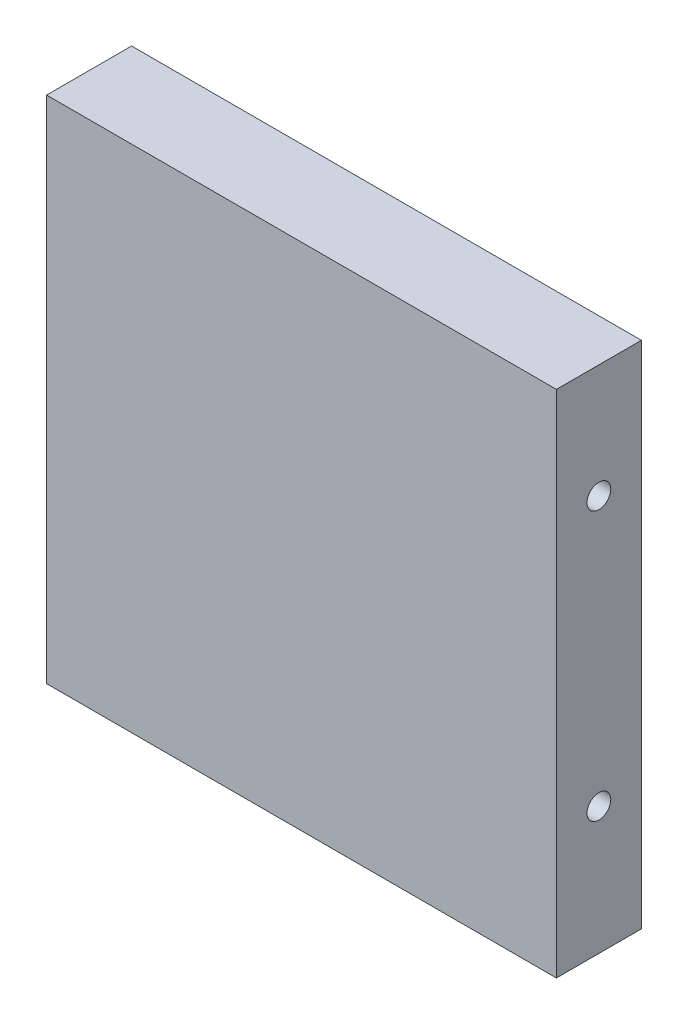
from build123d import *

# Parameters (mm, degrees)
SKETCH1_W                     = 38.1
SKETCH1_H                     = 38.1
BOSS_EXTRUDE1_DEPTH           = 6.35
TAP_DRILL_FOR_2_64_TAP1_D     = 1.778
TAP_DRILL_FOR_2_64_TAP1_DEPTH = 7.62
TAP_DRILL_FOR_2_64_TAP1_TIP   = 0.53416509
TAP_DRILL_FOR_2_64_TAP2_D     = 1.778
TAP_DRILL_FOR_2_64_TAP2_DEPTH = 7.62
TAP_DRILL_FOR_2_64_TAP2_TIP   = 0.53416509


with BuildPart() as part:
    # Sketch1 → Boss-Extrude1 (new body)
    with BuildSketch(Plane.XY):
        Rectangle(SKETCH1_W, SKETCH1_H)
    extrude(amount=BOSS_EXTRUDE1_DEPTH)

    # Tap Drill for #2-64 Tap1
    with Locations(Plane(origin=(0, -19.05, 0), x_dir=(-1, 0, 0), z_dir=(0, -1, 0))):
        with Locations((-15.24, -2.6029), (15.24, -2.6029)):
            Hole(TAP_DRILL_FOR_2_64_TAP1_D / 2, depth=TAP_DRILL_FOR_2_64_TAP1_DEPTH)
            with Locations((0, 0, -(TAP_DRILL_FOR_2_64_TAP1_DEPTH + TAP_DRILL_FOR_2_64_TAP1_TIP / 2))):  # 118° drill point
                Cone(0, TAP_DRILL_FOR_2_64_TAP1_D / 2, TAP_DRILL_FOR_2_64_TAP1_TIP, mode=Mode.SUBTRACT)

    # Tap Drill for #2-64 Tap2
    with Locations(Plane(origin=(19.05, 0, 0), x_dir=(0, 0, -1), z_dir=(1, 0, 0))):
        with Locations((-3.175, 10.5664), (-3.175, -9.525)):
            Hole(TAP_DRILL_FOR_2_64_TAP2_D / 2, depth=TAP_DRILL_FOR_2_64_TAP2_DEPTH)
            with Locations((0, 0, -(TAP_DRILL_FOR_2_64_TAP2_DEPTH + TAP_DRILL_FOR_2_64_TAP2_TIP / 2))):  # 118° drill point
                Cone(0, TAP_DRILL_FOR_2_64_TAP2_D / 2, TAP_DRILL_FOR_2_64_TAP2_TIP, mode=Mode.SUBTRACT)


solid = part.part
